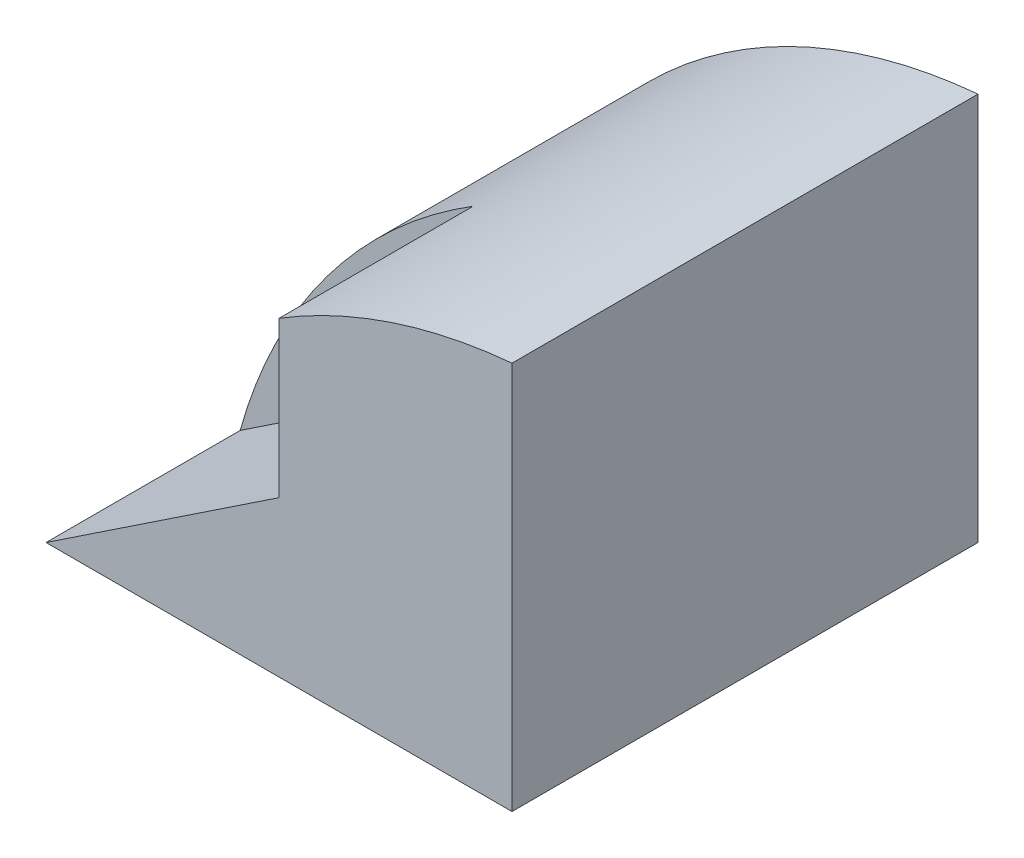
from build123d import *

# Parameters (mm, degrees)
SKETCH1_W           = 6
SKETCH1_H           = 6
BOSS_EXTRUDE1_DEPTH = 5
CUT_EXTRUDE10_DEPTH = 12.5
CUT_EXTRUDE11_DEPTH = 2.5


with BuildPart() as part:
    # Sketch1 → Boss-Extrude1 (new body)
    with BuildSketch(Plane(origin=(0, 0, 0), x_dir=(1, 0, 0), z_dir=(0, 1, 0))):
        Rectangle(SKETCH1_W, SKETCH1_H)
    extrude(amount=BOSS_EXTRUDE1_DEPTH)

    # Sketch11 → Cut-Extrude10 (cut)
    with BuildSketch(Plane.XY.offset(3)):
        with BuildLine():
            ThreePointArc((-3, 0), (-0.780941195, 3.437129434), (3, 5))
            Line((3, 5), (-3, 5))
            Line((-3, 5), (-3, 0))
        make_face()
    extrude(amount=-CUT_EXTRUDE10_DEPTH, mode=Mode.SUBTRACT)

    # Sketch12 → Cut-Extrude11 (cut)
    with BuildSketch(Plane.XY.offset(3)):
        with BuildLine():
            Line((0, 2), (0, 4))
            ThreePointArc((0, 4), (-1.877372905, 2.283029678), (-3, 0))
            Line((-3, 0), (0, 2))
        make_face()
    extrude(amount=-CUT_EXTRUDE11_DEPTH, mode=Mode.SUBTRACT)


solid = part.part
